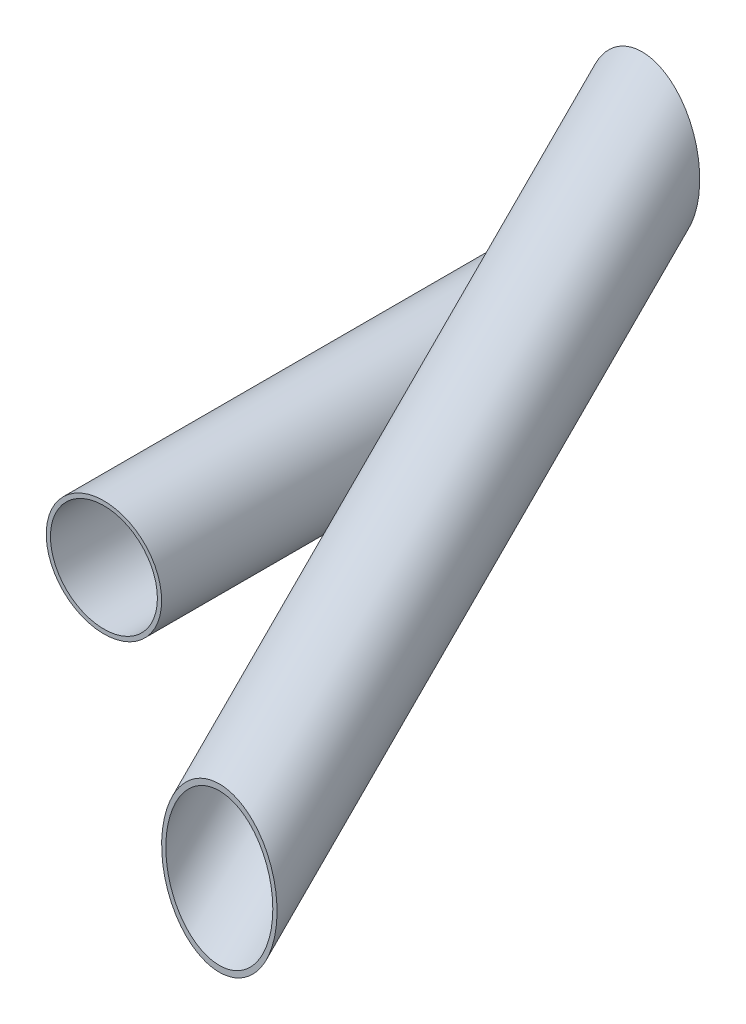
from build123d import *

# Parameters (mm, degrees)
ESQUISSE1_R                    = 13.65
ESQUISSE1_R_2                  = 12.65
BOSS_EXTRU_1_DEPTH             = 50
BOSS_EXTRU_6_REACH             = 85.361
ESQUISSE15_R                   = 13.65
ESQUISSE15_R_2                 = 12.65
BOSS_EXTRU_6_DIRECTION_2_REACH = 85.361


with BuildPart() as part:
    # Esquisse1 → Boss.-Extru.1 (new, symmetric)
    with BuildSketch(Plane.XY):
        Circle(ESQUISSE1_R)
        Circle(ESQUISSE1_R_2, mode=Mode.SUBTRACT)
    extrude(amount=BOSS_EXTRU_1_DEPTH, both=True)


with BuildPart() as body_2:
    # Boss.-Extru.6: up to this plane
    boss_extru_6_end = Plane(origin=(0, 0, 50), z_dir=(0, 0, 1))
    # Esquisse15 → Boss.-Extru.6 (new, up to the surface)
    with BuildSketch(Plane(origin=(0, 0, 0), x_dir=(1, 0, 0), z_dir=(0, -0.7071067811865488, 0.7071067811865464)), mode=Mode.PRIVATE) as boss_extru_6_sk1:
        with Locations(Location((27.3, 0, 0), (0, 0, 90))):
            Circle(ESQUISSE15_R)
        with Locations(Location((27.3, 0, 0), (0, 0, 90))):
            Circle(ESQUISSE15_R_2, mode=Mode.SUBTRACT)
    boss_extru_6_tool1 = split(extrude(boss_extru_6_sk1.sketch, amount=BOSS_EXTRU_6_REACH, mode=Mode.PRIVATE), bisect_by=boss_extru_6_end, keep=Keep.BOTH, mode=Mode.PRIVATE)
    add(boss_extru_6_tool1.solids().sort_by_distance((27.3, -9.379008, -9.379008))[0])

    # Boss.-Extru.6 direction 2: up to this plane
    boss_extru_6_direction_2_end = Plane(origin=(0, 0, -50), z_dir=(0, 0, 1))
    # Esquisse15 → Boss.-Extru.6 direction 2 (add, up to the surface)
    with BuildSketch(Plane(origin=(0, 0, 0), x_dir=(1, 0, 0), z_dir=(0, -0.7071067811865488, 0.7071067811865464)), mode=Mode.PRIVATE) as boss_extru_6_direction_2_sk1:
        with Locations(Location((27.3, 0, 0), (0, 0, 90))):
            Circle(ESQUISSE15_R)
        with Locations(Location((27.3, 0, 0), (0, 0, 90))):
            Circle(ESQUISSE15_R_2, mode=Mode.SUBTRACT)
    boss_extru_6_direction_2_tool1 = split(extrude(boss_extru_6_direction_2_sk1.sketch, amount=-BOSS_EXTRU_6_DIRECTION_2_REACH, mode=Mode.PRIVATE), bisect_by=boss_extru_6_direction_2_end, keep=Keep.BOTH, mode=Mode.PRIVATE)
    add(boss_extru_6_direction_2_tool1.solids().sort_by_distance((27.3, -9.379008, -9.379008))[0])


solid = Compound([part.part, body_2.part])
